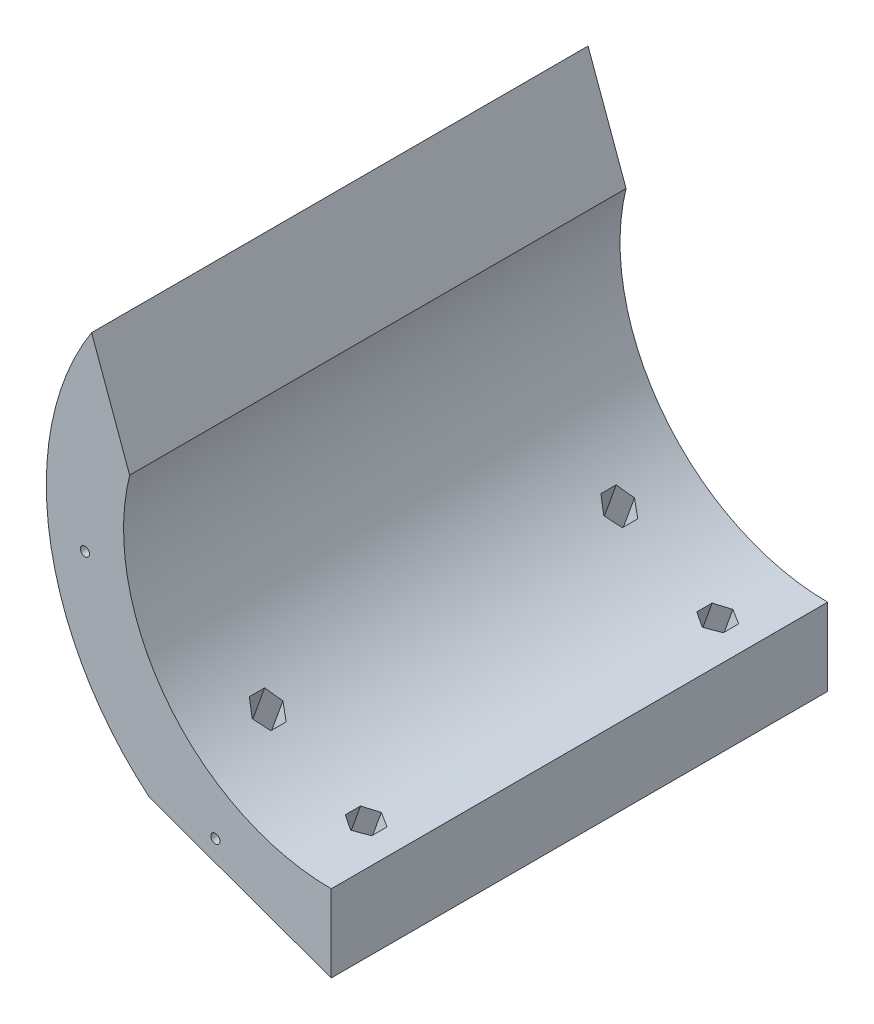
from build123d import *

# Parameters (mm, degrees)
BOSS_EXTRUDE1_DEPTH = 102.8
CUT_EXTRUDE1_DEPTH  = 103.8
CUT_EXTRUDE2_DEPTH  = 103.8
CUT_EXTRUDE3_REACH  = 87.538
SKETCH5_R           = 1.65
CUT_EXTRUDE4_START  = -5
CUT_EXTRUDE4_DEPTH  = 81.538495947
SKETCH7_R           = 0.95
CUT_EXTRUDE5_DEPTH  = 103.8


with BuildPart() as part:
    # Sketch1 → Boss-Extrude1 (new body)
    with BuildSketch(Plane.XY):
        with BuildLine():
            Line((0, 59), (0, 43))
            ThreePointArc((0, 43), (-43, 0), (0, -43))
            Line((0, -43), (0, -59))
            ThreePointArc((0, -59), (-59, 0), (0, 59))
        make_face()
    extrude(amount=BOSS_EXTRUDE1_DEPTH)

    # Sketch3 → Cut-Extrude1 (cut, through all)
    with BuildSketch(Plane.XY.offset(102.8)):
        Polygon((0, 0), (0, 90), (-70.757321084, 90), (-38, 0), align=None)
    extrude(amount=-CUT_EXTRUDE1_DEPTH, mode=Mode.SUBTRACT)

    # Sketch4 → Cut-Extrude2 (cut, through all)
    with BuildSketch(Plane.XY.offset(102.8)):
        Polygon((0, -59), (-37.631699217, -45.440677966), (-42.517346633, -59), align=None)
    extrude(amount=-CUT_EXTRUDE2_DEPTH, mode=Mode.SUBTRACT)

    # Sketch5 → Cut-Extrude3 (cut, up to next)
    with BuildSketch(Plane(origin=(-18.815849609, -52.220338983, 0), x_dir=(0.94079248, -0.338983051, 0), z_dir=(-0.338983051, -0.94079248, 0)), mode=Mode.PRIVATE) as cut_extrude3_sk1:
        with Locations((7, 15)):
            Circle(SKETCH5_R)
    cut_extrude3_tool1 = extrude(cut_extrude3_sk1.sketch, amount=-CUT_EXTRUDE3_REACH, mode=Mode.PRIVATE) & part.part
    add(cut_extrude3_tool1.solids().sort_by_distance((-12.230302, -54.59322, 15))[0], mode=Mode.SUBTRACT)
    # Sketch5 → Cut-Extrude3 (cut, up to next)
    with BuildSketch(Plane(origin=(-18.815849609, -52.220338983, 0), x_dir=(0.94079248, -0.338983051, 0), z_dir=(-0.338983051, -0.94079248, 0)), mode=Mode.PRIVATE) as cut_extrude3_sk2:
        with Locations((-15.5, 15)):
            Circle(SKETCH5_R)
    cut_extrude3_tool2 = extrude(cut_extrude3_sk2.sketch, amount=-CUT_EXTRUDE3_REACH, mode=Mode.PRIVATE) & part.part
    add(cut_extrude3_tool2.solids().sort_by_distance((-33.398133, -46.966102, 15))[0], mode=Mode.SUBTRACT)
    # Sketch5 → Cut-Extrude3 (cut, up to next)
    with BuildSketch(Plane(origin=(-18.815849609, -52.220338983, 0), x_dir=(0.94079248, -0.338983051, 0), z_dir=(-0.338983051, -0.94079248, 0)), mode=Mode.PRIVATE) as cut_extrude3_sk3:
        with Locations((-15.5, 87.8)):
            Circle(SKETCH5_R)
    cut_extrude3_tool3 = extrude(cut_extrude3_sk3.sketch, amount=-CUT_EXTRUDE3_REACH, mode=Mode.PRIVATE) & part.part
    add(cut_extrude3_tool3.solids().sort_by_distance((-33.398133, -46.966102, 87.8))[0], mode=Mode.SUBTRACT)
    # Sketch5 → Cut-Extrude3 (cut, up to next)
    with BuildSketch(Plane(origin=(-18.815849609, -52.220338983, 0), x_dir=(0.94079248, -0.338983051, 0), z_dir=(-0.338983051, -0.94079248, 0)), mode=Mode.PRIVATE) as cut_extrude3_sk4:
        with Locations((7, 87.8)):
            Circle(SKETCH5_R)
    cut_extrude3_tool4 = extrude(cut_extrude3_sk4.sketch, amount=-CUT_EXTRUDE3_REACH, mode=Mode.PRIVATE) & part.part
    add(cut_extrude3_tool4.solids().sort_by_distance((-12.230302, -54.59322, 87.8))[0], mode=Mode.SUBTRACT)

    # Sketch6 → Cut-Extrude4 (cut, through all)
    with BuildSketch(Plane(origin=(-18.815849609, -52.220338983, 0), x_dir=(0.94079248, -0.338983051, 0), z_dir=(-0.338983051, -0.94079248, 0)).offset(CUT_EXTRUDE4_START)):
        Polygon((7, 11.824573519), (9.75, 13.41228676), (9.75, 16.58771324), (7, 18.175426481), (4.25, 16.58771324), (4.25, 13.41228676), align=None)
        Polygon((-15.5, 11.824573519), (-12.75, 13.41228676), (-12.75, 16.58771324), (-15.5, 18.175426481), (-18.25, 16.58771324), (-18.25, 13.41228676), align=None)
        Polygon((-18.25, 89.38771324), (-15.5, 90.975426481), (-12.75, 89.38771324), (-12.75, 86.21228676), (-15.5, 84.624573519), (-18.25, 86.21228676), align=None)
        Polygon((4.25, 89.38771324), (7, 90.975426481), (9.75, 89.38771324), (9.75, 86.21228676), (7, 84.624573519), (4.25, 86.21228676), align=None)
    extrude(amount=-CUT_EXTRUDE4_DEPTH, mode=Mode.SUBTRACT)

    # Sketch7 → Cut-Extrude5 (cut, through all)
    with BuildSketch(Plane(origin=(0, 0, 0), x_dir=(-1, 0, 0), z_dir=(0, 0, -1))):
        with Locations((24, -46)):
            Circle(SKETCH7_R)
        with Locations((51, -8)):
            Circle(SKETCH7_R)
    extrude(amount=-CUT_EXTRUDE5_DEPTH, mode=Mode.SUBTRACT)


solid = part.part
